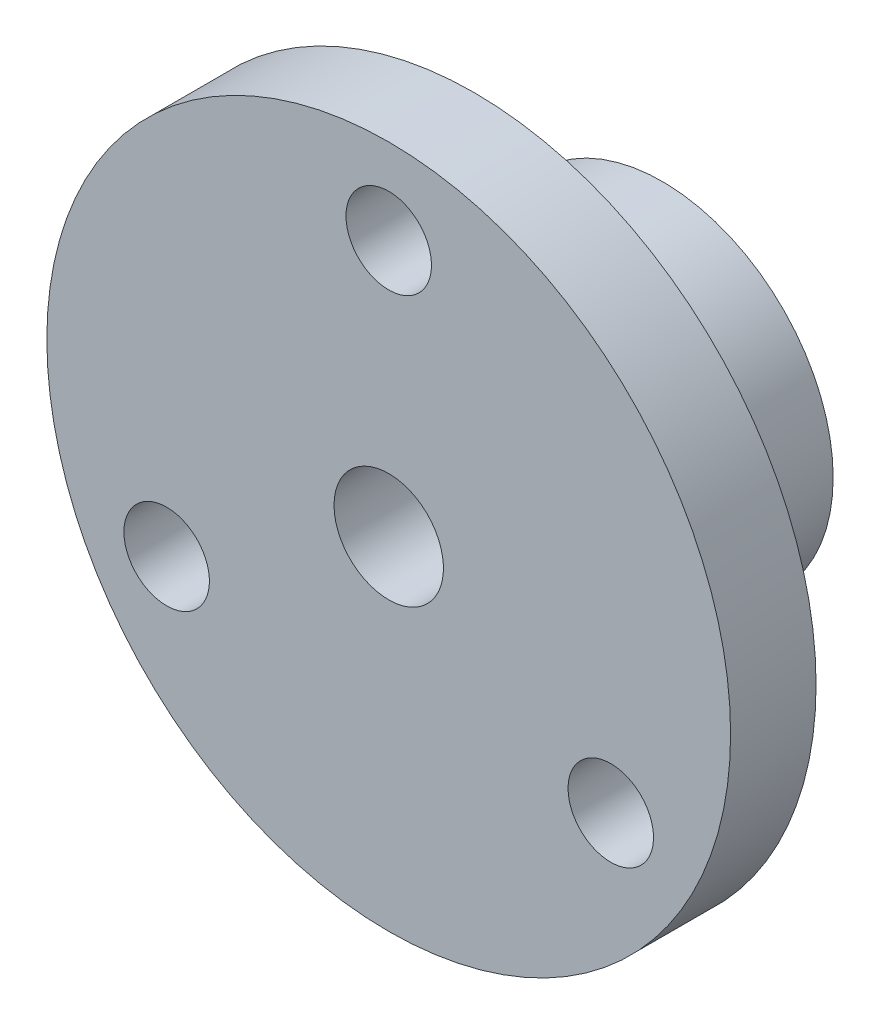
from build123d import *

# Parameters (mm, degrees)
SKETCH3_R                   = 4.064
CUT_EXTRUDE1_DEPTH          = 21.32
F_1_4_20_TAPPED_HOLE1_D     = 5.1054
F_1_4_20_TAPPED_HOLE1_DEPTH = 10.16
F_1_4_20_TAPPED_HOLE1_TIP   = 1.533816902
CIRPATTERN1_COUNT           = 3


with BuildPart() as part:
    # Sketch1 → Revolve1 (revolve)
    with BuildSketch(Plane(origin=(0, 0, 0), x_dir=(0, 0, -1), z_dir=(1, 0, 0))):
        Polygon((0, 12.7), (-13.97, 12.7), (-13.97, 25.4), (-20.32, 25.4), (-20.32, 0), (0, 0), align=None)
    revolve(axis=Axis((0, 0, 20.32), (0, 0, -1)))

    # Sketch3 → Cut-Extrude1 (cut, through all)
    with BuildSketch(Plane(origin=(0, 0, 0), x_dir=(-1, 0, 0), z_dir=(0, 0, -1))):
        Circle(SKETCH3_R)
    extrude(amount=-CUT_EXTRUDE1_DEPTH, mode=Mode.SUBTRACT)

    # 1/4-20 Tapped Hole1
    with Locations(Plane(origin=(0, 12.7, 7.62), x_dir=(1, 0, 0), z_dir=(0, 1, 0))):
        with Locations((0, 0)):
            Hole(F_1_4_20_TAPPED_HOLE1_D / 2, depth=F_1_4_20_TAPPED_HOLE1_DEPTH)
            with Locations((0, 0, -(F_1_4_20_TAPPED_HOLE1_DEPTH + F_1_4_20_TAPPED_HOLE1_TIP / 2))):  # 118° drill point
                Cone(0, F_1_4_20_TAPPED_HOLE1_D / 2, F_1_4_20_TAPPED_HOLE1_TIP, mode=Mode.SUBTRACT)

    # Sketch7 → 1/4 (0.25) Diameter Hole1 (revolve, cut)
    with BuildSketch(Plane(origin=(0, 19.05, 13.97), x_dir=(0, 1, 0), z_dir=(1, 0, 0))):
        Polygon((0, 0), (0, 20.957732465), (3.175, 19.05), (3.175, 0), align=None)
    f_1_4_0_25_diameter_hole1 = revolve(axis=Axis((0, 19.05, 7.62), (0, 0, 1)), mode=Mode.SUBTRACT)

    # CirPattern1: 1/4 (0.25) Diameter Hole1 ×3 about axis
    cirpattern1_axis = Axis((0, 0, 0), (0, 0, 1))
    for i in range(1, CIRPATTERN1_COUNT):
        add(f_1_4_0_25_diameter_hole1.rotate(cirpattern1_axis, i * 360 / CIRPATTERN1_COUNT), mode=Mode.SUBTRACT)


solid = part.part
